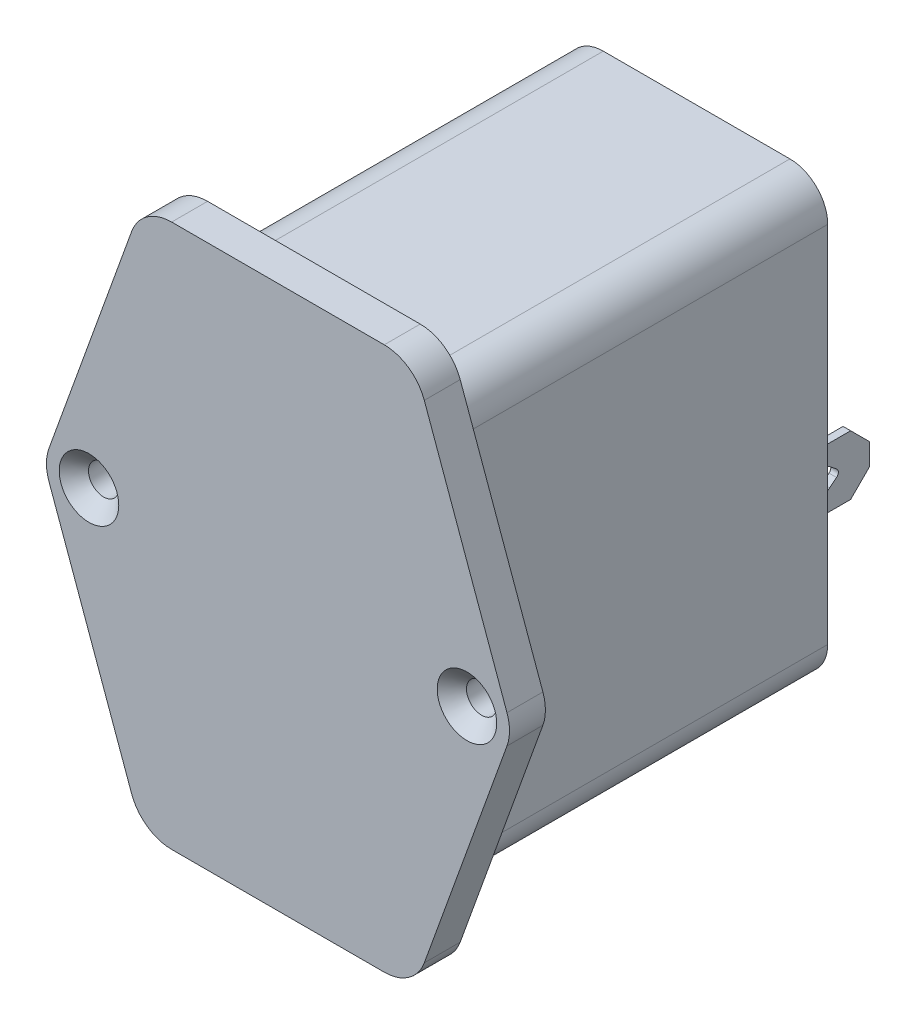
from build123d import *

# Parameters (mm, degrees)
SKETCH1_W                                       = 27.75
SKETCH1_H                                       = 46.5
BOSS_EXTRUDE1_DEPTH                             = 40.5
SKETCH2_R                                       = 1.6
BOSS_EXTRUDE2_DEPTH                             = 3.8
CSK_FOR_M3_FLAT_HEAD_MACHINE_SCREW1_D           = 3.2
CSK_FOR_M3_FLAT_HEAD_MACHINE_SCREW1_CSINK_D     = 6.3
CSK_FOR_M3_FLAT_HEAD_MACHINE_SCREW1_CSINK_ANGLE = 90
SKETCH5_W                                       = 5.5
SKETCH5_H                                       = 9.3
BOSS_EXTRUDE3_DEPTH                             = 2.5
BOSS_EXTRUDE4_DEPTH                             = 0.8
CHAMFER1_SIZE                                   = 2
FILLET1_R                                       = 0.5
SKETCH7_W                                       = 9
SKETCH7_H                                       = 6.3
BOSS_EXTRUDE5_DEPTH                             = 0.8
CHAMFER2_SIZE                                   = 2
FILLET3_R                                       = 0.5
FILLET2_R                                       = 4


with BuildPart() as part:
    # Sketch1 → Boss-Extrude1 (new body)
    with BuildSketch(Plane.XY):
        with Locations((13.875, 23.25)):
            Rectangle(SKETCH1_W, SKETCH1_H)
    extrude(amount=BOSS_EXTRUDE1_DEPTH)

    # Sketch2 → Boss-Extrude2 (add)
    with BuildSketch(Plane.XY.offset(40.5)):
        with BuildLine():
            Line((2.625, -5.2), (25.125, -5.2))
            ThreePointArc((25.125, -5.2), (27.711215896, -4.382592475), (29.357879644, -2.227327706))
            Line((29.357879644, -2.227327706), (38.107879644, 22.022672294))
            ThreePointArc((38.107879644, 22.022672294), (38.375, 23.55), (38.107879644, 25.077327706))
            Line((38.107879644, 25.077327706), (29.357879644, 49.327327706))
            ThreePointArc((29.357879644, 49.327327706), (27.711215896, 51.482592475), (25.125, 52.3))
            Line((25.125, 52.3), (2.625, 52.3))
            ThreePointArc((2.625, 52.3), (0.038784104, 51.482592475), (-1.607879644, 49.327327706))
            Line((-1.607879644, 49.327327706), (-10.357879644, 25.077327706))
            ThreePointArc((-10.357879644, 25.077327706), (-10.625, 23.55), (-10.357879644, 22.022672294))
            Line((-10.357879644, 22.022672294), (-1.607879644, -2.227327706))
            ThreePointArc((-1.607879644, -2.227327706), (0.038784104, -4.382592475), (2.625, -5.2))
        make_face()
        with Locations((-6.125, 23.55)):
            Circle(SKETCH2_R, mode=Mode.SUBTRACT)
        with Locations((33.875, 23.55)):
            Circle(SKETCH2_R, mode=Mode.SUBTRACT)
    extrude(amount=BOSS_EXTRUDE2_DEPTH)

    # CSK for M3 Flat Head Machine Screw1 (through all)
    with Locations(Plane.XY.offset(44.3)):
        with Locations((-6.125, 23.55), (33.875, 23.55)):
            CounterSinkHole(CSK_FOR_M3_FLAT_HEAD_MACHINE_SCREW1_D / 2, CSK_FOR_M3_FLAT_HEAD_MACHINE_SCREW1_CSINK_D / 2, counter_sink_angle=CSK_FOR_M3_FLAT_HEAD_MACHINE_SCREW1_CSINK_ANGLE)

    # Sketch5 → Boss-Extrude3 (add)
    with BuildSketch(Plane(origin=(0, 0, 0), x_dir=(-1, 0, 0), z_dir=(0, 0, -1))):
        with Locations((-20.225, 12.15)):
            Rectangle(SKETCH5_W, SKETCH5_H)
        with Locations((-7.525, 12.15)):
            Rectangle(SKETCH5_W, SKETCH5_H)
    extrude(amount=BOSS_EXTRUDE3_DEPTH)

    # Fillet2
    fillet2_edges = [part.edges().sort_by_distance(p)[0] for p in [
        (0, 46.5, 20.25),
        (27.75, 46.5, 20.25),
        (27.75, 0, 20.25),
        (0, 0, 20.25),
    ]]
    fillet(fillet2_edges, radius=FILLET2_R)


with BuildPart() as body_2:
    # Sketch6 → Boss-Extrude4 (new body)
    with BuildSketch(Plane(origin=(0, 5, 0), x_dir=(-1, 0, 0), z_dir=(0, -1, 0))):
        Polygon((-17.81, 0), (-17.81, 2.87), (-17.025, 2.87), (-17.025, 11.5), (-10.725, 11.5), (-10.725, 2.87), (-9.94, 2.87), (-9.94, 0), align=None)
        with BuildLine():
            Line((-13.875, 8.5), (-14.850780937, 7.28125))
            ThreePointArc((-14.850780937, 7.28125), (-13.875, 5.25), (-12.899219063, 7.28125))
            Line((-12.899219063, 7.28125), (-13.875, 8.5))
        make_face(mode=Mode.SUBTRACT)
    extrude(amount=BOSS_EXTRUDE4_DEPTH)

    # Chamfer1
    chamfer1_edges = [body_2.edges().sort_by_distance(p)[0] for p in [
        (17.025, 4.6, -11.5),
        (10.725, 4.6, -11.5),
    ]]
    chamfer(chamfer1_edges, length=CHAMFER1_SIZE)

    # Fillet1
    fillet1_edges = [body_2.edges().sort_by_distance(p)[0] for p in [
        (13.875, 4.6, -8.5),
    ]]
    fillet(fillet1_edges, radius=FILLET1_R)


with BuildPart() as body_3:
    # Sketch7 → Boss-Extrude5 (new body)
    with BuildSketch(Plane(origin=(19.875, 0, 0), x_dir=(0, 0, -1), z_dir=(1, 0, 0))):
        with Locations((7, 12.15)):
            Rectangle(SKETCH7_W, SKETCH7_H)
        with BuildLine():
            Line((7.28125, 13.125780937), (8.5, 12.15))
            Line((8.5, 12.15), (7.28125, 11.174219063))
            ThreePointArc((7.28125, 11.174219063), (5.25, 12.15), (7.28125, 13.125780937))
        make_face(mode=Mode.SUBTRACT)
    extrude(amount=BOSS_EXTRUDE5_DEPTH)

    # Chamfer2
    chamfer2_edges = [body_3.edges().sort_by_distance(p)[0] for p in [
        (20.275, 15.3, -11.5),
        (20.275, 9, -11.5),
    ]]
    chamfer(chamfer2_edges, length=CHAMFER2_SIZE)

    # Fillet3
    fillet3_edges = [body_3.edges().sort_by_distance(p)[0] for p in [
        (20.275, 12.15, -8.5),
    ]]
    fillet(fillet3_edges, radius=FILLET3_R)


with BuildPart() as body_4:
    # Mirror2: mirrored copy
    add(body_3.part.mirror(Plane(origin=(13.875, 0, 0), x_dir=(0, 0, 1), z_dir=(1, 0, 0))))


solid = Compound([part.part, body_2.part, body_3.part, body_4.part])
